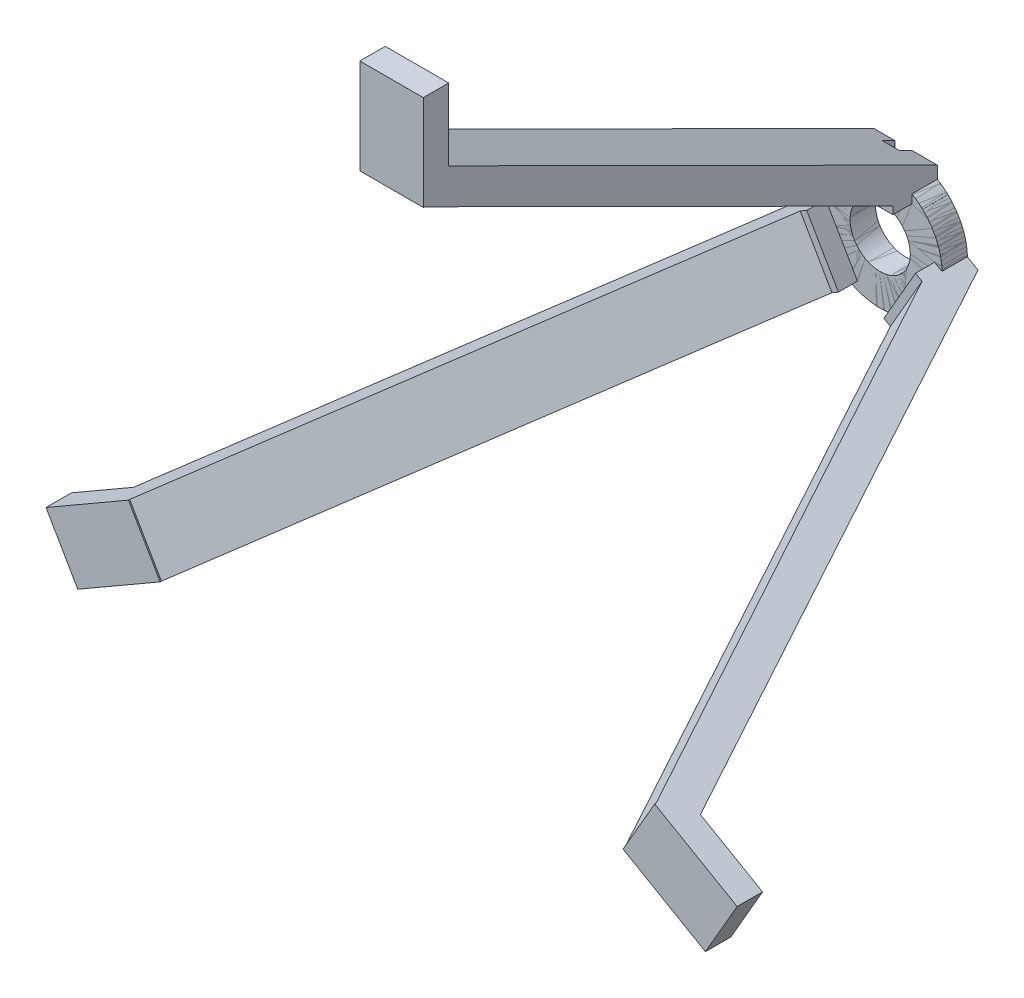
from build123d import *

# Parameters (mm, degrees)
SKETCH1_R                = 4.75
BOSS_EXTRUDE1_DEPTH      = 4
SKETCH2_W                = 10
SKETCH2_H                = 3.269716928
BOSS_EXTRUDE3_DEPTH      = 3
BOSS_EXTRUDE3_DEPTH_BACK = 2
SKETCH6_W                = 10
SKETCH6_H                = 15
BOSS_EXTRUDE4_DEPTH      = 4
BOSS_EXTRUDE5_DEPTH      = 10
CIRPATTERN2_COUNT        = 3
SKETCH8_W                = 2.673559767
SKETCH8_H                = 4.657077396
CUT_EXTRUDE2_DEPTH       = 2
CUT_EXTRUDE2_DEPTH_BACK  = 2


with BuildPart() as part:
    # Sketch1 → Boss-Extrude1 (new body)
    with BuildSketch(Plane.XY):
        with BuildLine():
            Line((6.690811411, 7.091935043), (-6.690811411, 7.091935043))
            ThreePointArc((-6.690811411, 7.091935043), (-3.861805843, -8.95259491), (9.75, 0))
            ThreePointArc((9.75, 0), (8.95259491, 3.861805843), (6.690811411, 7.091935043))
        make_face()
        Circle(SKETCH1_R, mode=Mode.SUBTRACT)
    extrude(amount=BOSS_EXTRUDE1_DEPTH)

    # Sketch2 → Boss-Extrude3 (add, two sides)
    with BuildSketch(Plane.XY.offset(4)) as boss_extrude3_sk:
        with Locations((0, 8.652125422)):
            Rectangle(SKETCH2_W, SKETCH2_H)
    extrude(amount=BOSS_EXTRUDE3_DEPTH)
    extrude(boss_extrude3_sk.sketch, amount=-BOSS_EXTRUDE3_DEPTH_BACK)



with BuildPart() as body_2:
    # Sketch6 → Boss-Extrude4 (new body)
    with BuildSketch(Plane.XY.offset(81)):
        with Locations((0, 52.5)):
            Rectangle(SKETCH6_W, SKETCH6_H)
    extrude(amount=-BOSS_EXTRUDE4_DEPTH)


with BuildPart() as part_1:
    add(part.part)

    add(body_2.part)  # Boss-Extrude5 merges body 2
    # Sketch7 → Boss-Extrude5 (add)
    with BuildSketch(Plane.ZY.offset(5)):
        Polygon((-0.002733191, 10.292464872), (77, 48.691244479), (80.802029792, 45), (7, 8.197307951), (7, 7.017266958), (0, 7.091935043), align=None)
    extrude(amount=-BOSS_EXTRUDE5_DEPTH)


with BuildPart() as cirpattern2_1:
    # CirPattern2: pattern copy
    add(part_1.part.rotate(Axis((0, 0, 0), (0, 0, 1)), 1 * 360 / CIRPATTERN2_COUNT))


with BuildPart() as cirpattern2_2:
    # CirPattern2: pattern copy
    add(part_1.part.rotate(Axis((0, 0, 0), (0, 0, 1)), 2 * 360 / CIRPATTERN2_COUNT))


with BuildPart() as cut_extrude2_tool:
    # Sketch8 → Cut-Extrude2 (new body, two sides)
    with BuildSketch(Plane(origin=(0, 0, 0), x_dir=(-1, 0, 0), z_dir=(0, 0, -1))) as cut_extrude2_sk:
        with Locations((0.321098697, 9.274223879)):
            Rectangle(SKETCH8_W, SKETCH8_H)
    extrude(amount=CUT_EXTRUDE2_DEPTH)
    extrude(cut_extrude2_sk.sketch, amount=-CUT_EXTRUDE2_DEPTH_BACK)


with BuildPart() as part_2:
    add(part_1.part)

    # Cut-Extrude2: cut by cut_extrude2_tool
    add(cut_extrude2_tool.part, mode=Mode.SUBTRACT)


with BuildPart() as cirpattern2_1_1:
    add(cirpattern2_1.part)

    # Cut-Extrude2: cut by cut_extrude2_tool
    add(cut_extrude2_tool.part, mode=Mode.SUBTRACT)


with BuildPart() as cirpattern2_2_1:
    add(cirpattern2_2.part)

    # Cut-Extrude2: cut by cut_extrude2_tool
    add(cut_extrude2_tool.part, mode=Mode.SUBTRACT)


solid = Compound([part_2.part, cirpattern2_1_1.part, cirpattern2_2_1.part])
